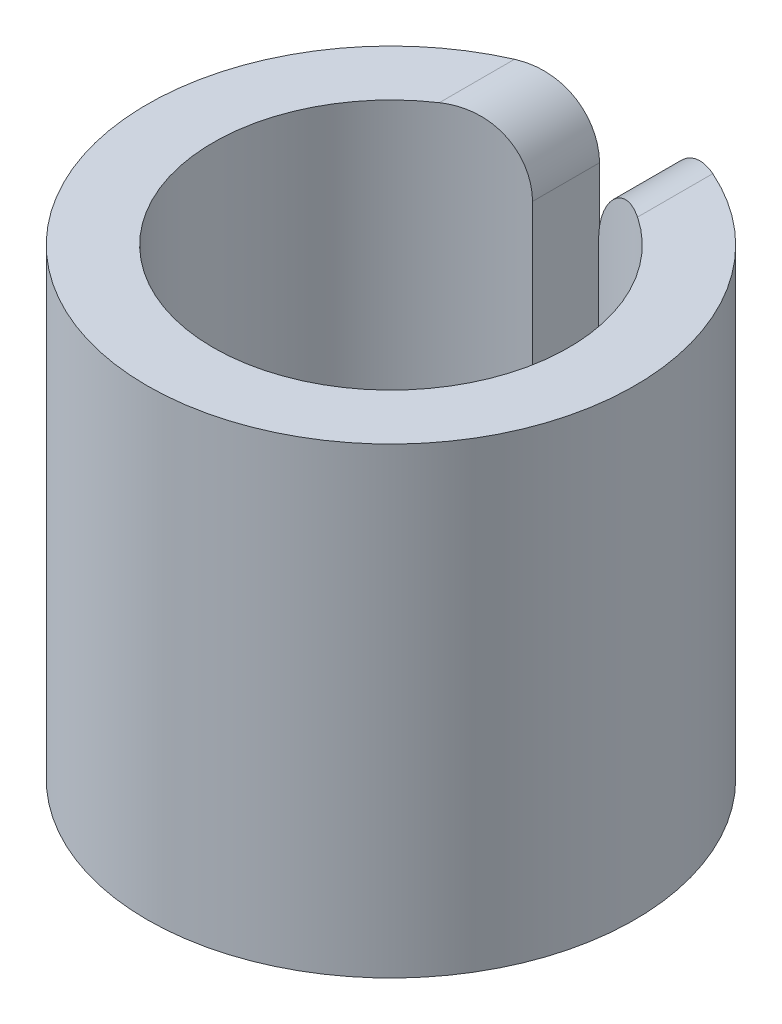
from build123d import *

# Parameters (mm, degrees)
SKETCH3_R               = 3.69
SKETCH3_R_2             = 2.69
EXTRUDE_THIN1_DEPTH     = 3.5
SKETCH4_W               = 1
SKETCH4_H               = 1000
CUT_EXTRUDE1_DEPTH      = 4.5
CUT_EXTRUDE1_DEPTH_BACK = 4.5
FILLET1_R               = 1


with BuildPart() as part:
    # Sketch3 → Extrude-Thin1 (new body, symmetric)
    with BuildSketch(Plane(origin=(0, 0, 0), x_dir=(1, 0, 0), z_dir=(0, 1, 0))):
        Circle(SKETCH3_R)
        Circle(SKETCH3_R_2, mode=Mode.SUBTRACT)
    extrude(amount=EXTRUDE_THIN1_DEPTH, both=True)

    # Sketch4 → Cut-Extrude1 (cut, two sides)
    with BuildSketch(Plane(origin=(0, 0, 0), x_dir=(1, 0, 0), z_dir=(0, 1, 0))) as cut_extrude1_sk:
        with Locations((0, 500)):
            Rectangle(SKETCH4_W, SKETCH4_H)
    extrude(amount=CUT_EXTRUDE1_DEPTH, mode=Mode.SUBTRACT)
    extrude(cut_extrude1_sk.sketch, amount=-CUT_EXTRUDE1_DEPTH_BACK, mode=Mode.SUBTRACT)

    # Fillet1
    fillet1_edges = [part.edges().sort_by_distance(p)[0] for p in [
        (0.5, -3.5, -3.149545438),
        (-0.5, -3.5, -3.149545438),
        (0.5, 3.5, -3.149545438),
        (-0.5, 3.5, -3.149545438),
    ]]
    fillet(fillet1_edges, radius=FILLET1_R)


solid = part.part
